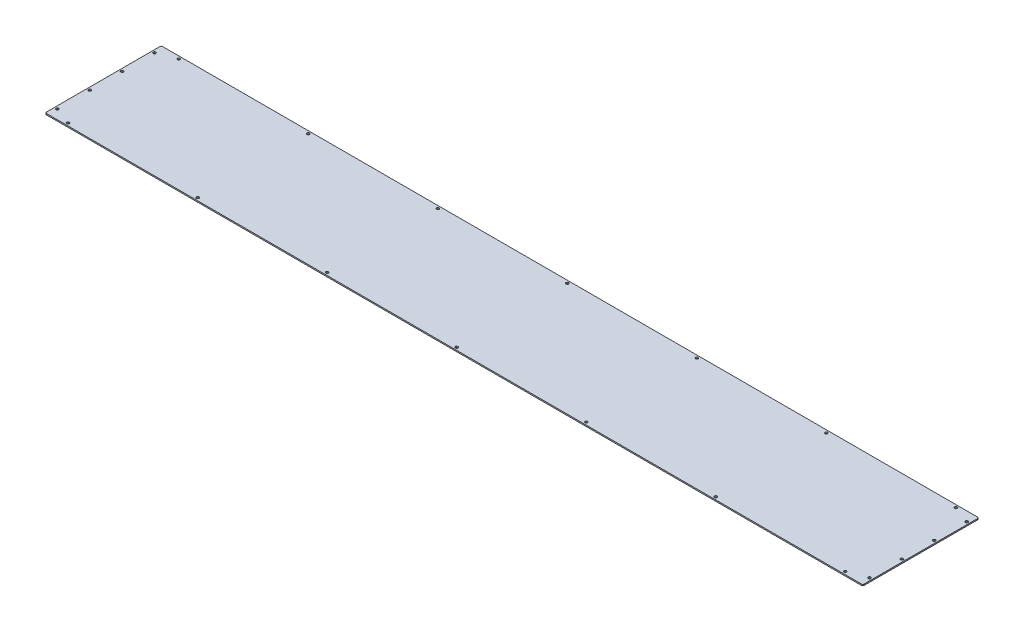
from build123d import *

# Parameters (mm, degrees)
SKETCH1_W                   = 1924.05
SKETCH1_H                   = 273.05
BOSS_EXTRUDE1_DEPTH         = 2.9972
FILLET1_R                   = 3.175
F_1_4_0_25_DIAMETER_HOLE1_D = 6.35


with BuildPart() as part:
    # Sketch1 → Boss-Extrude1 (new body)
    with BuildSketch(Plane(origin=(0, 0, 0), x_dir=(1, 0, 0), z_dir=(0, 1, 0))):
        Rectangle(SKETCH1_W, SKETCH1_H)
    extrude(amount=BOSS_EXTRUDE1_DEPTH)

    # Fillet1
    fillet1_edges = [part.edges().sort_by_distance(p)[0] for p in [
        (962.025, 1.4986, 136.525),
        (-962.025, 1.4986, 136.525),
        (-962.025, 1.4986, -136.525),
        (962.025, 1.4986, -136.525),
    ]]
    fillet(fillet1_edges, radius=FILLET1_R)

    # 1/4 (0.25) Diameter Hole1 (through all)
    with Locations(Plane(origin=(0, 2.9972, 0), x_dir=(1, 0, 0), z_dir=(0, 1, 0))):
        with Locations((0, -130.175), (-955.675, 38.1), (-955.675, -38.1), (-914.4, -130.175), (-609.6, -130.175), (-304.8, -130.175), (304.8, -130.175), (609.6, -130.175), (914.4, -130.175), (-955.675, -114.3), (914.4, 130.175), (609.6, 130.175), (304.8, 130.175), (-304.8, 130.175), (-609.6, 130.175), (-914.4, 130.175), (0, 130.175), (955.675, -114.3), (955.675, -38.1), (955.675, 38.1), (-955.675, 114.3), (955.675, 114.3)):
            Hole(F_1_4_0_25_DIAMETER_HOLE1_D / 2)


solid = part.part
